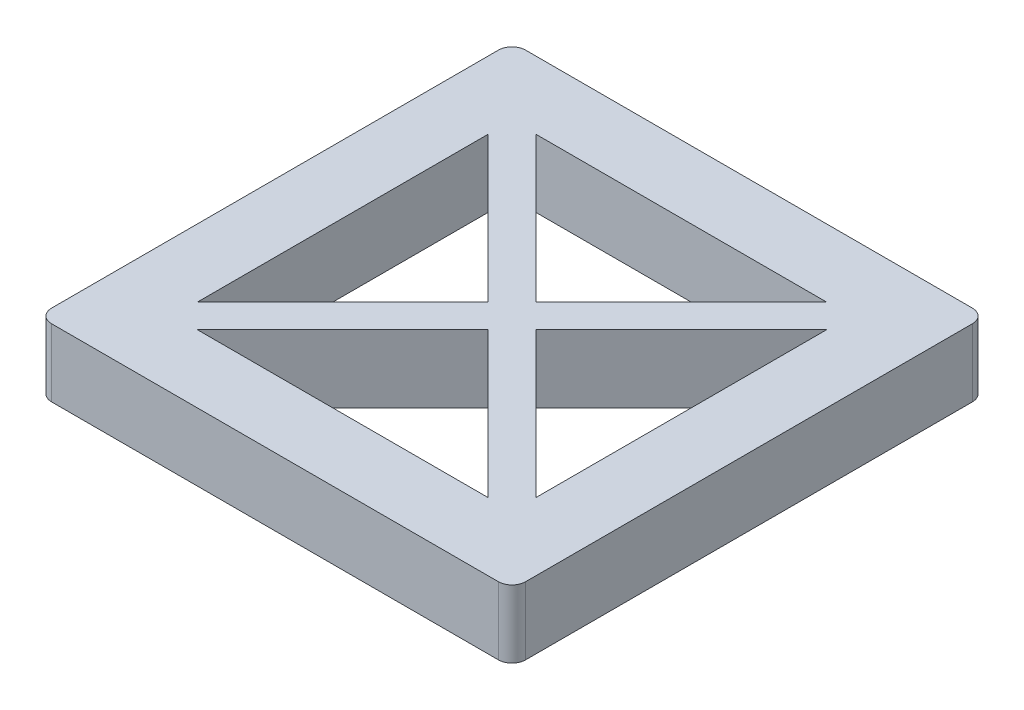
from build123d import *

# Parameters (mm, degrees)
SKETCH1_W           = 88.9
SKETCH1_H           = 88.9
SKETCH1_R           = 3.175
BOSS_EXTRUDE1_DEPTH = 9.525
SKETCH2_W           = 88.9
SKETCH2_H           = 88.9
BOSS_EXTRUDE2_DEPTH = 3.175
FILLET1_R           = 2.54


with BuildPart() as part:
    # Sketch1 → Boss-Extrude1 (new body)
    with BuildSketch(Plane(origin=(0, 0, 0), x_dir=(1, 0, 0), z_dir=(0, 1, 0))):
        with Locations((44.45, -44.45)):
            Rectangle(SKETCH1_W, SKETCH1_H)
        with Locations((6.35, -82.55)):
            Circle(SKETCH1_R, mode=Mode.SUBTRACT)
        with Locations((82.55, -82.55)):
            Circle(SKETCH1_R, mode=Mode.SUBTRACT)
        Polygon((71.709871939, -76.2), (17.190128061, -76.2), (44.45, -48.940128061), align=None, mode=Mode.SUBTRACT)
        Polygon((12.7, -71.709871939), (12.7, -17.190128061), (39.959871939, -44.45), align=None, mode=Mode.SUBTRACT)
        Polygon((44.45, -39.959871939), (17.190128061, -12.7), (71.709871939, -12.7), align=None, mode=Mode.SUBTRACT)
        with Locations((6.35, -6.35)):
            Circle(SKETCH1_R, mode=Mode.SUBTRACT)
        Polygon((48.940128061, -44.45), (76.2, -17.190128061), (76.2, -71.709871939), align=None, mode=Mode.SUBTRACT)
        with Locations((82.55, -6.35)):
            Circle(SKETCH1_R, mode=Mode.SUBTRACT)
    extrude(amount=BOSS_EXTRUDE1_DEPTH)

    # Sketch2 → Boss-Extrude2 (add)
    with BuildSketch(Plane(origin=(0, 9.525, 0), x_dir=(1, 0, 0), z_dir=(0, 1, 0))):
        with Locations((44.45, -44.45)):
            Rectangle(SKETCH2_W, SKETCH2_H)
        Polygon((44.45, -48.940128061), (71.709871939, -76.2), (17.190128061, -76.2), align=None, mode=Mode.SUBTRACT)
        Polygon((76.2, -17.190128061), (76.2, -71.709871939), (48.940128061, -44.45), align=None, mode=Mode.SUBTRACT)
        Polygon((44.45, -39.959871939), (71.709871939, -12.7), (17.190128061, -12.7), align=None, mode=Mode.SUBTRACT)
        Polygon((12.7, -71.709871939), (39.959871939, -44.45), (12.7, -17.190128061), align=None, mode=Mode.SUBTRACT)
    extrude(amount=BOSS_EXTRUDE2_DEPTH)

    # Fillet1
    fillet1_edges = [part.edges().sort_by_distance(p)[0] for p in [
        (88.9, 6.35, 88.9),
        (0, 6.35, 88.9),
        (0, 6.35, 0),
        (88.9, 6.35, 0),
    ]]
    fillet(fillet1_edges, radius=FILLET1_R)


solid = part.part
